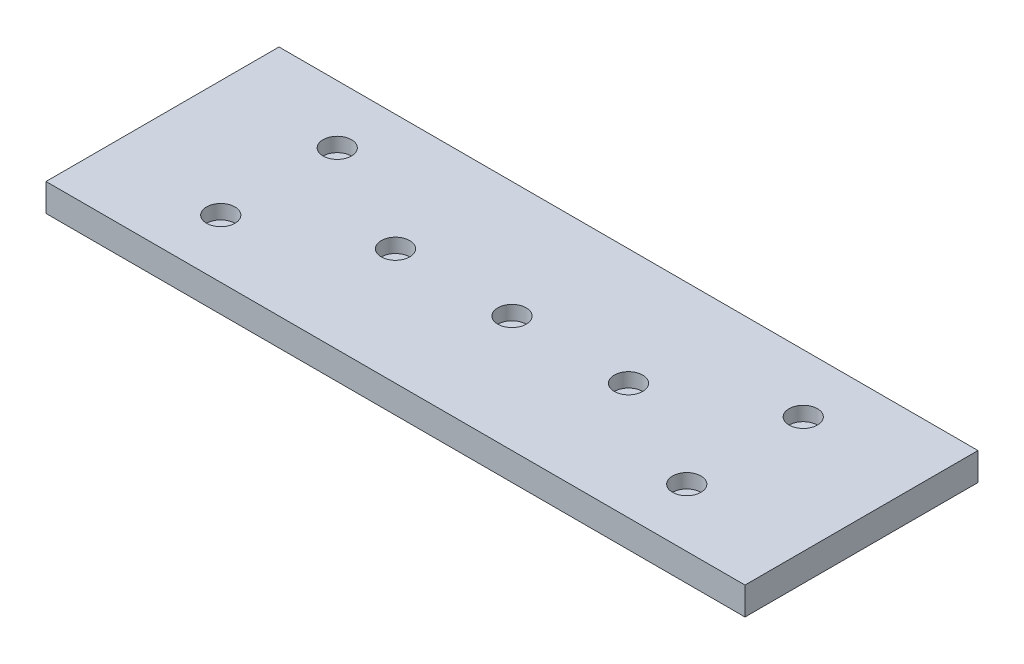
from build123d import *

# Parameters (mm, degrees)
SKETCH1_W           = 150
SKETCH1_H           = 50
BOSS_EXTRUDE1_DEPTH = 5.95
SKETCH2_R           = 3.05
CUT_EXTRUDE1_DEPTH  = 3.05


with BuildPart() as part:
    # Sketch1 → Boss-Extrude1 (new body)
    with BuildSketch(Plane(origin=(0, 0, 0), x_dir=(1, 0, 0), z_dir=(0, 1, 0))):
        with Locations((-75, 25)):
            Rectangle(SKETCH1_W, SKETCH1_H)
    extrude(amount=BOSS_EXTRUDE1_DEPTH)

    # Sketch2 → Cut-Extrude1 (cut)
    with BuildSketch(Plane(origin=(0, 5.95, 0), x_dir=(1, 0, 0), z_dir=(0, 1, 0))):
        with Locations((-25, 37.5)):
            Circle(SKETCH2_R)
        with Locations((-25, 12.5)):
            Circle(SKETCH2_R)
        with Locations((-50, 25)):
            Circle(SKETCH2_R)
        with Locations((-75, 25)):
            Circle(SKETCH2_R)
        with Locations((-100, 25)):
            Circle(SKETCH2_R)
        with Locations((-125, 12.5)):
            Circle(SKETCH2_R)
        with Locations((-125, 37.5)):
            Circle(SKETCH2_R)
    extrude(amount=-CUT_EXTRUDE1_DEPTH, mode=Mode.SUBTRACT)


solid = part.part
